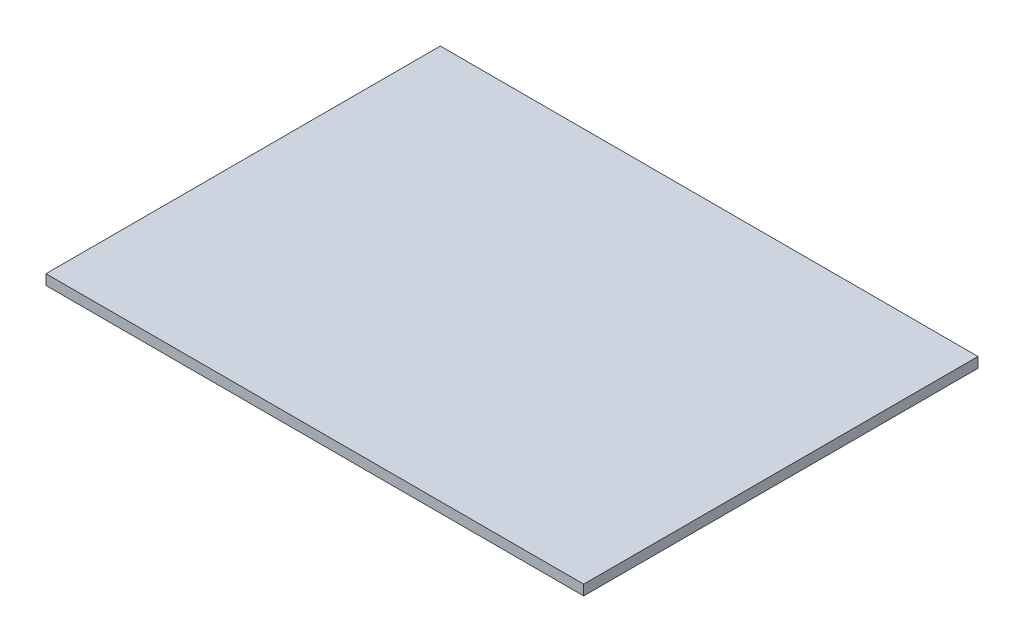
from build123d import *

# Parameters (mm, degrees)
SKETCH2_W           = 105
SKETCH2_H           = 77
BOSS_EXTRUDE1_DEPTH = 2


with BuildPart() as part:
    # Sketch2 → Boss-Extrude1 (new body)
    with BuildSketch(Plane(origin=(0, 0, 0), x_dir=(1, 0, 0), z_dir=(0, 1, 0))):
        Rectangle(SKETCH2_W, SKETCH2_H)
    extrude(amount=BOSS_EXTRUDE1_DEPTH)


solid = part.part
